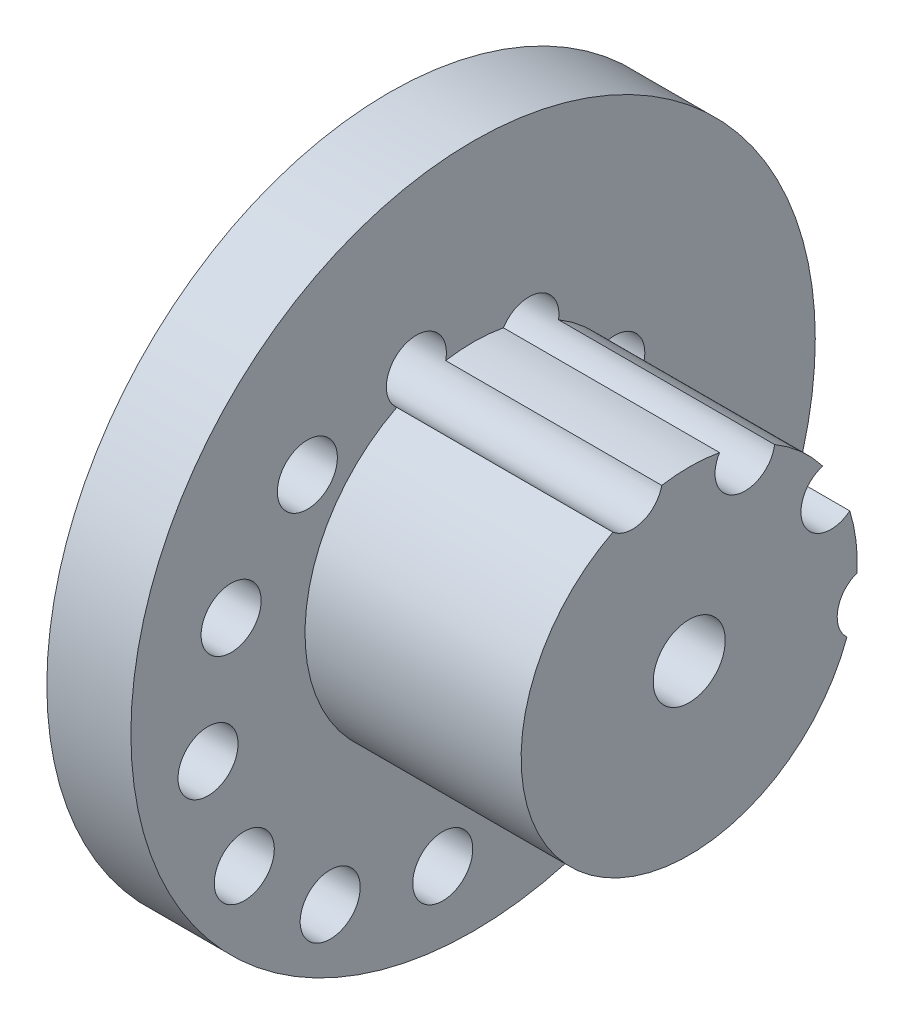
from build123d import *

# Parameters (mm, degrees)
SKETCH1_R               = 28.5
SKETCH1_R_2             = 14
BOSS_EXTRUDE1_DEPTH     = 7
SKETCH1_4_R             = 14
SKETCH1_4_R_2           = 3
BOSS_EXTRUDE2_DEPTH     = 25
CUT_EXTRUDE1_DEPTH      = 48.428894147
CUT_EXTRUDE1_DEPTH_BACK = 48.428894147
SKETCH3_R               = 2.5


with BuildPart() as part:
    # Sketch1 → Boss-Extrude1 (new body)
    with BuildSketch(Plane(origin=(0, 0, 0), x_dir=(0, 0, -1), z_dir=(1, 0, 0))):
        Circle(SKETCH1_R)
        Circle(SKETCH1_R_2, mode=Mode.SUBTRACT)
    extrude(amount=BOSS_EXTRUDE1_DEPTH)

    # Sketch1_4 → Boss-Extrude2 (add)
    with BuildSketch(Plane(origin=(0, 0, 0), x_dir=(0, 0, -1), z_dir=(1, 0, 0))):
        Circle(SKETCH1_4_R)
        Circle(SKETCH1_4_R_2, mode=Mode.SUBTRACT)
    extrude(amount=BOSS_EXTRUDE2_DEPTH)

    # Sketch3 → Cut-Extrude1 (cut, two sides: drawn at the far end of the back side and taken through both)
    with BuildSketch(Plane.ZY.offset(-CUT_EXTRUDE1_DEPTH_BACK)):
        with Locations((19.055020887, -14.259950175)):
            Circle(SKETCH3_R)
        with Locations((11.9, -20.61140461)):
            Circle(SKETCH3_R)
        with Locations((2.52784293, -22.534415058)):
            Circle(SKETCH3_R)
        with Locations((-6.550188406, -19.513712423)):
            Circle(SKETCH3_R)
        with Locations((-12.901642841, -12.358691536)):
            Circle(SKETCH3_R)
        with Locations((-14.824653289, -2.986534466)):
            Circle(SKETCH3_R)
        with Locations((-11.803950653, 6.09149687)):
            Circle(SKETCH3_R)
        with Locations((-4.648929766, 12.442951305)):
            Circle(SKETCH3_R)
        with Locations((4.723227304, 14.365961753)):
            Circle(SKETCH3_R)
        with Locations((13.801258639, 11.345259118)):
            Circle(SKETCH3_R)
        with Locations((20.152713074, 4.19023823)):
            Circle(SKETCH3_R)
        with Locations((22.075723522, -5.18191884)):
            Circle(SKETCH3_R)
    extrude(amount=CUT_EXTRUDE1_DEPTH + CUT_EXTRUDE1_DEPTH_BACK, mode=Mode.SUBTRACT)


solid = part.part
